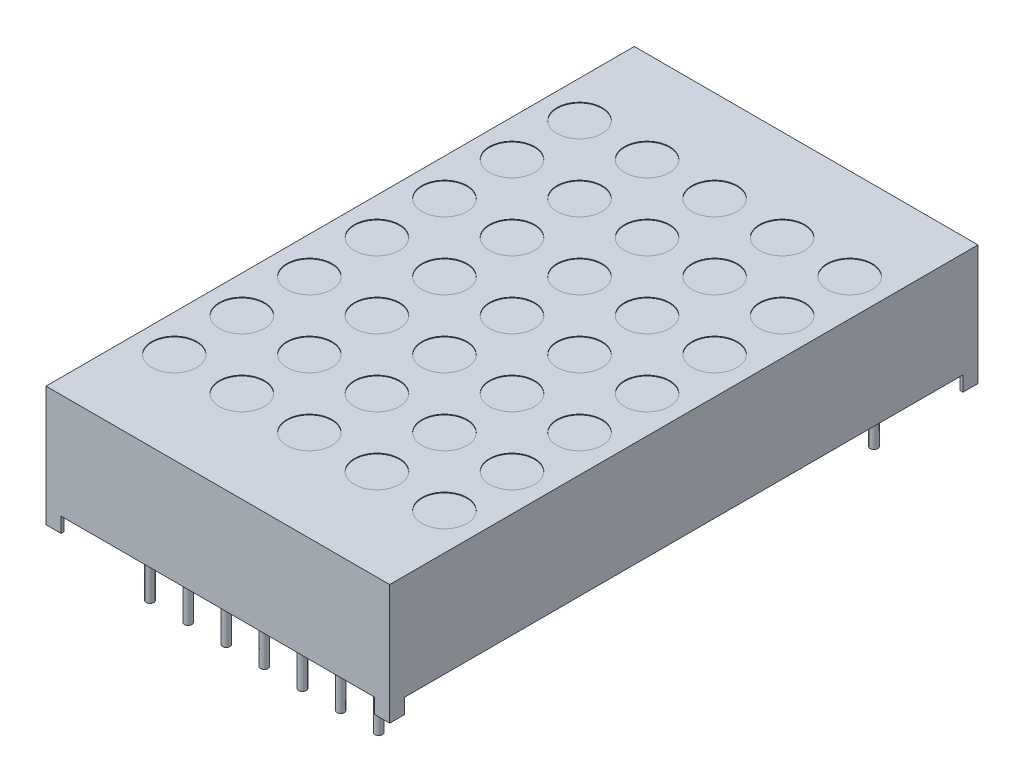
from build123d import *
from build123d.topology import SkipClean

# Parameters (mm, degrees)
EXTRUDE1_DEPTH     = 11.45
SKETCH3_W          = 20.9
SKETCH3_H          = 1
CUT_EXTRUDE1_DEPTH = 40.2
SKETCH2_R          = 1.5
CUT_EXTRUDE2_DEPTH = 0.05
SKETCH4_R          = 0.25
EXTRUDE2_DEPTH     = 1
SKETCH4_3_R        = 0.25
EXTRUDE3_DEPTH     = 4
SKETCH4_4_W        = 0.8
SKETCH4_4_H        = 0.8
CUT_EXTRUDE3_DEPTH = 1
SKETCH5_W          = 0.025316456
SKETCH5_H          = 0.026582279
CUT_EXTRUDE4_DEPTH = 0.01


with BuildPart() as part:
    # Sketch1 → Extrude1 (new body, symmetric)
    with BuildSketch(Plane(origin=(0, 0, 0), x_dir=(0, 0, -1), z_dir=(1, 0, 0))):
        Polygon((19.6, 4), (-19.6, 4), (14.7, -3), (18.6, -3), (18.6, -3.795918367), (19.6, -4), align=None)
        Polygon((14.7, -3), (-19.6, 4), (-19.6, -4), (-18.6, -4), (-18.6, -3), align=None)
        Polygon((19.6, -4), (18.6, -3.795918367), (18.6, -4), align=None)
    extrude(amount=EXTRUDE1_DEPTH, both=True)

    # Sketch3 → Cut-Extrude1 (cut, through all)
    with BuildSketch(Plane.XY.offset(19.6)):
        with Locations((0, -3.5)):
            Rectangle(SKETCH3_W, SKETCH3_H)
    extrude(amount=-CUT_EXTRUDE1_DEPTH, mode=Mode.SUBTRACT)

    # Sketch2 → Cut-Extrude2 (cut)
    with BuildSketch(Plane(origin=(0, 4, 0), x_dir=(-1, 0, 0), z_dir=(0, 1, 0))):
        with Locations(Location((9, -13.5, 0), (0, 0, 90))):  # turned: the seam where the file's is
            Circle(SKETCH2_R)
        with Locations(Location((4.5, -13.5, 0), (0, 0, 90))):  # turned: the seam where the file's is
            Circle(SKETCH2_R)
        with Locations(Location((0, -13.5, 0), (0, 0, 90))):  # turned: the seam where the file's is
            Circle(SKETCH2_R)
        with Locations(Location((-4.5, -13.5, 0), (0, 0, 90))):  # turned: the seam where the file's is
            Circle(SKETCH2_R)
        with Locations(Location((-9, -13.5, 0), (0, 0, 90))):  # turned: the seam where the file's is
            Circle(SKETCH2_R)
        with Locations(Location((-9, -9, 0), (0, 0, 90))):  # turned: the seam where the file's is
            Circle(SKETCH2_R)
        with Locations(Location((-4.5, -9, 0), (0, 0, 90))):  # turned: the seam where the file's is
            Circle(SKETCH2_R)
        with Locations(Location((0, -9, 0), (0, 0, 90))):  # turned: the seam where the file's is
            Circle(SKETCH2_R)
        with Locations(Location((4.5, -9, 0), (0, 0, 90))):  # turned: the seam where the file's is
            Circle(SKETCH2_R)
        with Locations(Location((9, -9, 0), (0, 0, 90))):  # turned: the seam where the file's is
            Circle(SKETCH2_R)
        with Locations(Location((9, -4.5, 0), (0, 0, 90))):  # turned: the seam where the file's is
            Circle(SKETCH2_R)
        with Locations(Location((4.5, -4.5, 0), (0, 0, 90))):  # turned: the seam where the file's is
            Circle(SKETCH2_R)
        with Locations(Location((0, -4.5, 0), (0, 0, 90))):  # turned: the seam where the file's is
            Circle(SKETCH2_R)
        with Locations(Location((-4.5, -4.5, 0), (0, 0, 90))):  # turned: the seam where the file's is
            Circle(SKETCH2_R)
        with Locations(Location((-9, -4.5, 0), (0, 0, 90))):  # turned: the seam where the file's is
            Circle(SKETCH2_R)
        with Locations(Location((-9, 0, 0), (0, 0, 90))):  # turned: the seam where the file's is
            Circle(SKETCH2_R)
        with Locations(Location((-4.5, 0, 0), (0, 0, 90))):  # turned: the seam where the file's is
            Circle(SKETCH2_R)
        with Locations(Location((0, 0, 0), (0, 0, 90))):  # turned: the seam where the file's is
            Circle(SKETCH2_R)
        with Locations(Location((4.5, 0, 0), (0, 0, 90))):  # turned: the seam where the file's is
            Circle(SKETCH2_R)
        with Locations(Location((9, 0, 0), (0, 0, 90))):  # turned: the seam where the file's is
            Circle(SKETCH2_R)
        with Locations(Location((9, 4.5, 0), (0, 0, 90))):  # turned: the seam where the file's is
            Circle(SKETCH2_R)
        with Locations(Location((4.5, 4.5, 0), (0, 0, 90))):  # turned: the seam where the file's is
            Circle(SKETCH2_R)
        with Locations(Location((0, 4.5, 0), (0, 0, 90))):  # turned: the seam where the file's is
            Circle(SKETCH2_R)
        with Locations(Location((-4.5, 4.5, 0), (0, 0, 90))):  # turned: the seam where the file's is
            Circle(SKETCH2_R)
        with Locations(Location((-9, 4.5, 0), (0, 0, 90))):  # turned: the seam where the file's is
            Circle(SKETCH2_R)
        with Locations(Location((-9, 9, 0), (0, 0, 90))):  # turned: the seam where the file's is
            Circle(SKETCH2_R)
        with Locations(Location((-4.5, 9, 0), (0, 0, 90))):  # turned: the seam where the file's is
            Circle(SKETCH2_R)
        with Locations(Location((0, 9, 0), (0, 0, 90))):  # turned: the seam where the file's is
            Circle(SKETCH2_R)
        with Locations(Location((4.5, 9, 0), (0, 0, 90))):  # turned: the seam where the file's is
            Circle(SKETCH2_R)
        with Locations(Location((9, 9, 0), (0, 0, 90))):  # turned: the seam where the file's is
            Circle(SKETCH2_R)
        with Locations(Location((9, 13.5, 0), (0, 0, 90))):  # turned: the seam where the file's is
            Circle(SKETCH2_R)
        with Locations(Location((4.5, 13.5, 0), (0, 0, 90))):  # turned: the seam where the file's is
            Circle(SKETCH2_R)
        with Locations(Location((0, 13.5, 0), (0, 0, 90))):  # turned: the seam where the file's is
            Circle(SKETCH2_R)
        with Locations(Location((-4.5, 13.5, 0), (0, 0, 90))):  # turned: the seam where the file's is
            Circle(SKETCH2_R)
        with Locations(Location((-9, 13.5, 0), (0, 0, 90))):  # turned: the seam where the file's is
            Circle(SKETCH2_R)
    extrude(amount=-CUT_EXTRUDE2_DEPTH, mode=Mode.SUBTRACT)

    # Sketch4 → Extrude2 (add)
    with BuildSketch(Plane.XZ.offset(4)):
        with Locations((-7.62, 16.5)):
            Circle(SKETCH4_R)
        with Locations(Location((-5.08, 16.5, 0), (0, 0, 90))):  # turned: the seam where the file's is
            Circle(SKETCH4_R)
        with Locations(Location((-2.54, 16.5, 0), (0, 0, 90))):  # turned: the seam where the file's is
            Circle(SKETCH4_R)
        with Locations(Location((7.62, 16.5, 0), (0, 0, 90))):  # turned: the seam where the file's is
            Circle(SKETCH4_R)
        with Locations(Location((0, 16.5, 0), (0, 0, 90))):  # turned: the seam where the file's is
            Circle(SKETCH4_R)
        with Locations(Location((2.54, 16.5, 0), (0, 0, 90))):  # turned: the seam where the file's is
            Circle(SKETCH4_R)
        with Locations(Location((5.08, 16.5, 0), (0, 0, 90))):  # turned: the seam where the file's is
            Circle(SKETCH4_R)
        with Locations(Location((5.08, -16.5, 0), (0, 0, 90))):  # turned: the seam where the file's is
            Circle(SKETCH4_R)
        with Locations(Location((2.54, -16.5, 0), (0, 0, 90))):  # turned: the seam where the file's is
            Circle(SKETCH4_R)
        with Locations(Location((0, -16.5, 0), (0, 0, 90))):  # turned: the seam where the file's is
            Circle(SKETCH4_R)
        with Locations(Location((7.62, -16.5, 0), (0, 0, 90))):  # turned: the seam where the file's is
            Circle(SKETCH4_R)
        with Locations(Location((-2.54, -16.5, 0), (0, 0, 90))):  # turned: the seam where the file's is
            Circle(SKETCH4_R)
        with Locations(Location((-5.08, -16.5, 0), (0, 0, 90))):  # turned: the seam where the file's is
            Circle(SKETCH4_R)
        with Locations(Location((-7.62, -16.5, 0), (0, 0, 90))):  # turned: the seam where the file's is
            Circle(SKETCH4_R)
    extrude(amount=-EXTRUDE2_DEPTH)

    # Sketch4_3 → Extrude3 (add)
    with SkipClean():  # keep this step's faces unmerged: merging them makes the solid invalid here
        with BuildSketch(Plane.XZ.offset(4)):
            with Locations((-7.62, 16.5)):
                Circle(SKETCH4_3_R)
            with Locations((-5.08, 16.5)):
                Circle(SKETCH4_3_R)
            with Locations((-2.54, 16.5)):
                Circle(SKETCH4_3_R)
            with Locations((7.62, 16.5)):
                Circle(SKETCH4_3_R)
            with Locations((0, 16.5)):
                Circle(SKETCH4_3_R)
            with Locations((2.54, 16.5)):
                Circle(SKETCH4_3_R)
            with Locations(Location((5.08, 16.5, 0), (0, 0, 90))):  # turned: the seam where the file's is
                Circle(SKETCH4_3_R)
            with Locations(Location((5.08, -16.5, 0), (0, 0, 180))):  # turned: the seam where the file's is
                Circle(SKETCH4_3_R)
            with Locations(Location((2.54, -16.5, 0), (0, 0, 180))):  # turned: the seam where the file's is
                Circle(SKETCH4_3_R)
            with Locations(Location((0, -16.5, 0), (0, 0, 180))):  # turned: the seam where the file's is
                Circle(SKETCH4_3_R)
            with Locations(Location((7.62, -16.5, 0), (0, 0, 180))):  # turned: the seam where the file's is
                Circle(SKETCH4_3_R)
            with Locations(Location((-2.54, -16.5, 0), (0, 0, 90))):  # turned: the seam where the file's is
                Circle(SKETCH4_3_R)
            with Locations(Location((-5.08, -16.5, 0), (0, 0, 90))):  # turned: the seam where the file's is
                Circle(SKETCH4_3_R)
            with Locations(Location((-7.62, -16.5, 0), (0, 0, 90))):  # turned: the seam where the file's is
                Circle(SKETCH4_3_R)
        extrude(amount=EXTRUDE3_DEPTH)

    # Sketch4_4 → Cut-Extrude3 (cut)
    with SkipClean():  # keep this step's faces unmerged: merging them makes the solid invalid here
        with BuildSketch(Plane.XZ.offset(4)):
            with Locations((-10.85, 19)):
                Rectangle(SKETCH4_4_W, SKETCH4_4_H)
            with Locations((10.85, 19)):
                Rectangle(SKETCH4_4_W, SKETCH4_4_H)
            with Locations((10.85, -19)):
                Rectangle(SKETCH4_4_W, SKETCH4_4_H)
            with Locations((-10.85, -19)):
                Rectangle(SKETCH4_4_W, SKETCH4_4_H)
        extrude(amount=-CUT_EXTRUDE3_DEPTH, mode=Mode.SUBTRACT)

    # Sketch5 → Cut-Extrude4 (cut)
    with SkipClean():  # keep this step's faces unmerged: merging them makes the solid invalid here
        with BuildSketch(Plane.XZ.offset(3)):
            Polygon((0.572151899, 16.06631939), (0.595609177, 16.141002935), (0.620352057, 16.141002935), (0.636768196, 16.0906667), (0.652294304, 16.141002935), (0.678026108, 16.141002935), (0.701265823, 16.06631939), (0.676087816, 16.06631939), (0.663093354, 16.117802776), (0.646677215, 16.06631939), (0.625178006, 16.06631939), (0.608860759, 16.117802776), (0.596044304, 16.06631939), align=None)
            Polygon((0.437974684, 16.06631939), (0.461431962, 16.141002935), (0.486174842, 16.141002935), (0.502590981, 16.0906667), (0.518117089, 16.141002935), (0.543848892, 16.141002935), (0.567088608, 16.06631939), (0.541910601, 16.06631939), (0.528916139, 16.117802776), (0.5125, 16.06631939), (0.491000791, 16.06631939), (0.474683544, 16.117802776), (0.461867089, 16.06631939), align=None)
            Polygon((0.303797468, 16.06631939), (0.327254747, 16.141002935), (0.351997627, 16.141002935), (0.368413766, 16.0906667), (0.383939873, 16.141002935), (0.409671677, 16.141002935), (0.432911392, 16.06631939), (0.407733386, 16.06631939), (0.394738924, 16.117802776), (0.378322785, 16.06631939), (0.356823576, 16.06631939), (0.340506329, 16.117802776), (0.327689873, 16.06631939), align=None)
            with Locations((0.275949367, 16.127711795)):
                Rectangle(SKETCH5_W, SKETCH5_H)
            with BuildLine():
                add(Edge.make_bspline(
                    [(0.159493671, 16.109832048), (0.159530199, 16.111054163), (0.159601928, 16.113453987), (0.16021109, 16.116961953), (0.161206614, 16.120285236), (0.162570953, 16.123447952), (0.164384941, 16.126403318), (0.166539954, 16.129221885), (0.169151869, 16.131805846), (0.172088905, 16.134244608), (0.175386832, 16.136427002), (0.178989454, 16.138327141), (0.182859774, 16.139951859), (0.187013794, 16.141283549), (0.191459372, 16.142274316), (0.196177149, 16.142997634), (0.201170497, 16.143471141), (0.204594085, 16.143513083), (0.206348892, 16.14353458)],
                    knots=[0, 0, 0, 0, 0.907421153, 1.781872267, 2.635683434, 3.480115191, 4.332689235, 5.205575272, 6.109500117, 7.055808355, 8.037942167, 9.041423561, 10.07750834, 11.152467461, 12.277657752, 13.45734338, 14.696726425, 16, 16, 16, 16], degree=3))
                add(Edge.make_bspline(
                    [(0.206348892, 16.14353458), (0.208366877, 16.143507315), (0.212275063, 16.143454512), (0.217942631, 16.143069139), (0.223206098, 16.142381189), (0.228103845, 16.141424609), (0.232708145, 16.140221323), (0.23714149, 16.13893068), (0.241422782, 16.137466099), (0.244195874, 16.136365963), (0.24556962, 16.135820973)],
                    knots=[0, 0, 0, 0, 1.203182053, 2.33017619, 3.384818652, 4.366208123, 5.30340534, 6.221361684, 7.118890722, 8, 8, 8, 8], degree=3))
                Line((0.24556962, 16.135820973), (0.24556962, 16.11188901))
                Line((0.24556962, 16.11188901), (0.242721519, 16.11188901))
                add(Edge.make_bspline(
                    [(0.242721519, 16.11188901), (0.241355956, 16.112969973), (0.238632846, 16.115125552), (0.234205888, 16.117893907), (0.229546876, 16.120266917), (0.224708482, 16.12224954), (0.219807114, 16.123825154), (0.214938046, 16.124952059), (0.210169064, 16.125691424), (0.207010742, 16.125772985), (0.205458861, 16.125813061)],
                    knots=[0, 0, 0, 0, 1.030738938, 2.055426519, 3.085610749, 4.123842265, 5.148648843, 6.130724483, 7.081507926, 8, 8, 8, 8], degree=3))
                add(Edge.make_bspline(
                    [(0.205458861, 16.125813061), (0.205030115, 16.12581176), (0.204112202, 16.125808976), (0.202643054, 16.125687661), (0.200986711, 16.125559817), (0.199205972, 16.125363702), (0.197418768, 16.125132558), (0.19575852, 16.12478609), (0.194257758, 16.124416939), (0.193351089, 16.124049674), (0.192919304, 16.12387477)],
                    knots=[0, 0, 0, 0, 0.806537132, 1.726733348, 2.77251655, 3.932999672, 5.098049949, 6.161349231, 7.124375527, 8, 8, 8, 8], degree=3))
                add(Edge.make_bspline(
                    [(0.192919304, 16.12387477), (0.192439817, 16.123646534), (0.191497525, 16.123198003), (0.190194994, 16.122384093), (0.189024509, 16.121489348), (0.187963807, 16.120527615), (0.187101412, 16.119364627), (0.186480251, 16.117965356), (0.18613568, 16.116316063), (0.186096608, 16.115140901), (0.186075949, 16.114519548)],
                    knots=[0, 0, 0, 0, 1.02474257, 2.013837243, 2.958431669, 3.867978675, 4.769292696, 5.732237074, 6.800947934, 8, 8, 8, 8], degree=3))
                add(Edge.make_bspline(
                    [(0.186075949, 16.114519548), (0.186107411, 16.113973682), (0.186169273, 16.112900348), (0.186750779, 16.111371919), (0.187634826, 16.109951783), (0.188914241, 16.108686446), (0.190527919, 16.107560335), (0.192458907, 16.106549571), (0.194732757, 16.105713814), (0.19636997, 16.105275942), (0.197231013, 16.105045656)],
                    knots=[0, 0, 0, 0, 0.825427492, 1.623033598, 2.45033906, 3.348940377, 4.33183287, 5.428402891, 6.647546779, 8, 8, 8, 8], degree=3))
                add(Edge.make_bspline(
                    [(0.197231013, 16.105045656), (0.199200253, 16.104600451), (0.203235465, 16.103688173), (0.209375278, 16.102500719), (0.215513981, 16.101274849), (0.219470238, 16.100060534), (0.221400316, 16.099468124)],
                    knots=[0, 0, 0, 0, 0.976118991, 2.000185432, 3.024380873, 4, 4, 4, 4], degree=3))
                add(Edge.make_bspline(
                    [(0.221400316, 16.099468124), (0.222438469, 16.099114402), (0.224459331, 16.098425847), (0.227358523, 16.097273199), (0.230001771, 16.095968065), (0.23245931, 16.094646026), (0.234651974, 16.093165969), (0.236646608, 16.09163321), (0.238399268, 16.089980405), (0.239925706, 16.088230913), (0.241268572, 16.086394551), (0.242421982, 16.084447409), (0.243383004, 16.08238096), (0.244206396, 16.080225563), (0.244817623, 16.077951027), (0.245240059, 16.07557461), (0.245538122, 16.073091124), (0.245558978, 16.071396788), (0.24556962, 16.070532207)],
                    knots=[0, 0, 0, 0, 1.287376879, 2.505999703, 3.65855109, 4.746193839, 5.778582289, 6.760029101, 7.696159662, 8.601061861, 9.48181646, 10.363080883, 11.252765705, 12.153987336, 13.068239035, 14.012364187, 14.985753787, 16, 16, 16, 16], degree=3))
                add(Edge.make_bspline(
                    [(0.24556962, 16.070532207), (0.24553232, 16.06937606), (0.245458913, 16.067100785), (0.244857463, 16.063771763), (0.243830953, 16.060622944), (0.242444593, 16.057619788), (0.2406171, 16.054805525), (0.238424977, 16.052128039), (0.235814667, 16.049635543), (0.23282934, 16.047336906), (0.229542493, 16.0452581), (0.226008488, 16.043421393), (0.222229636, 16.041914945), (0.218249751, 16.040633714), (0.214030359, 16.039681319), (0.209593388, 16.038961741), (0.204919526, 16.038548741), (0.201728115, 16.038497465), (0.200098892, 16.038471289)],
                    knots=[0, 0, 0, 0, 0.894901293, 1.761149761, 2.608783409, 3.453876344, 4.314933854, 5.200038827, 6.12799933, 7.103249695, 8.113098521, 9.136064399, 10.182719798, 11.259667356, 12.370545059, 13.528828137, 14.738461593, 16, 16, 16, 16], degree=3))
                add(Edge.make_bspline(
                    [(0.200098892, 16.038471289), (0.198430241, 16.038493682), (0.195095767, 16.038538429), (0.190113794, 16.038913399), (0.185156379, 16.0394799), (0.180284815, 16.040279355), (0.175602308, 16.04129701), (0.171185694, 16.042382968), (0.167106724, 16.043623358), (0.164532999, 16.044577404), (0.163291139, 16.045037745)],
                    knots=[0, 0, 0, 0, 1.065379838, 2.128953261, 3.188461447, 4.250817766, 5.279613205, 6.247547721, 7.154416075, 8, 8, 8, 8], degree=3))
                Line((0.163291139, 16.045037745), (0.163291139, 16.067585213))
                Line((0.163291139, 16.067585213), (0.166119462, 16.067585213))
                add(Edge.make_bspline(
                    [(0.166119462, 16.067585213), (0.167192422, 16.066785009), (0.169386652, 16.065148571), (0.173045405, 16.063062595), (0.177009465, 16.061113081), (0.181274367, 16.059391287), (0.185746907, 16.057970687), (0.190324453, 16.056941642), (0.194951518, 16.056302519), (0.198053109, 16.056229387), (0.19960443, 16.056192808)],
                    knots=[0, 0, 0, 0, 0.89224925, 1.824673196, 2.804309561, 3.838364047, 4.890042674, 5.931526337, 6.965412421, 8, 8, 8, 8], degree=3))
                add(Edge.make_bspline(
                    [(0.19960443, 16.056192808), (0.20069973, 16.056217018), (0.202889476, 16.056265418), (0.206163883, 16.056614672), (0.209398675, 16.057286414), (0.211441573, 16.05810075), (0.212460443, 16.05850689)],
                    knots=[0, 0, 0, 0, 0.998993879, 1.997209027, 3.00113285, 4, 4, 4, 4], degree=3))
                add(Edge.make_bspline(
                    [(0.212460443, 16.05850689), (0.212893922, 16.058708373), (0.213760592, 16.059111204), (0.214967595, 16.05988353), (0.216070899, 16.060813248), (0.217071904, 16.061865642), (0.21791996, 16.063034977), (0.21855762, 16.064304736), (0.218918439, 16.065666714), (0.218964276, 16.066600883), (0.218987342, 16.067070973)],
                    knots=[0, 0, 0, 0, 1.005454979, 2.010239304, 3.005296729, 4.036100111, 5.060531193, 6.034954812, 7.011155677, 8, 8, 8, 8], degree=3))
                add(Edge.make_bspline(
                    [(0.218987342, 16.067070973), (0.218952547, 16.067708903), (0.218886059, 16.068927931), (0.218286061, 16.070641628), (0.217288392, 16.072104739), (0.216135293, 16.073097733), (0.215018314, 16.073796493), (0.213977797, 16.074301732), (0.212778346, 16.074815155), (0.211400897, 16.075304352), (0.209865762, 16.075798399), (0.20815684, 16.076273069), (0.206274232, 16.076722628), (0.204958342, 16.07700878), (0.204272152, 16.077157998)],
                    knots=[0, 0, 0, 0, 1.174343879, 2.244064321, 3.303704314, 4.407076671, 5.02483983, 5.732197225, 6.53898402, 7.431906431, 8.428480183, 9.514816237, 10.704066255, 12, 12, 12, 12], degree=3))
                add(Edge.make_bspline(
                    [(0.204272152, 16.077157998), (0.202439527, 16.077534718), (0.198838824, 16.07827489), (0.193433749, 16.079369187), (0.187940695, 16.080681704), (0.184270145, 16.081810916), (0.182357595, 16.082399295)],
                    knots=[0, 0, 0, 0, 0.995788186, 1.956503735, 2.935230479, 4, 4, 4, 4], degree=3))
                add(Edge.make_bspline(
                    [(0.182357595, 16.082399295), (0.181411038, 16.082718537), (0.179559421, 16.083343024), (0.176918823, 16.084429343), (0.17447165, 16.0856032), (0.172205016, 16.086845169), (0.17012965, 16.088187603), (0.16824336, 16.089612936), (0.166545403, 16.091117718), (0.165056655, 16.092733438), (0.163727897, 16.094443787), (0.162615553, 16.0962944), (0.161619968, 16.098237929), (0.160866813, 16.100331372), (0.160242304, 16.102529899), (0.159820561, 16.104861834), (0.159526198, 16.107306052), (0.159504634, 16.108980651), (0.159493671, 16.109832048)],
                    knots=[0, 0, 0, 0, 1.237326419, 2.420410185, 3.534642089, 4.598489486, 5.620241961, 6.59385002, 7.525152549, 8.426792174, 9.312230456, 10.203151844, 11.098070343, 12.012931196, 12.954244379, 13.926618287, 14.945853925, 16, 16, 16, 16], degree=3))
            make_face()
            with BuildLine():
                Line((0.067088608, 16.141002935), (0.091139241, 16.141002935))
                Line((0.091139241, 16.141002935), (0.091139241, 16.133170656))
                add(Edge.make_bspline(
                    [(0.091139241, 16.133170656), (0.092232434, 16.133979451), (0.094340096, 16.135538796), (0.097514655, 16.137615857), (0.100532955, 16.13940028), (0.103463307, 16.140923397), (0.106469584, 16.142135568), (0.109707718, 16.142953948), (0.113209314, 16.143456672), (0.115636384, 16.143508034), (0.116890823, 16.14353458)],
                    knots=[0, 0, 0, 0, 1.150945962, 2.219006967, 3.209666795, 4.118194914, 5.012574058, 5.946577101, 6.93868214, 8, 8, 8, 8], degree=3))
                add(Edge.make_bspline(
                    [(0.116890823, 16.14353458), (0.117907098, 16.143511632), (0.119886079, 16.143466946), (0.122764378, 16.143125225), (0.125466344, 16.142576816), (0.127995181, 16.14180841), (0.130344881, 16.140805379), (0.132488561, 16.139533744), (0.134491138, 16.138101031), (0.136273085, 16.136394665), (0.137888631, 16.134496746), (0.139271202, 16.132364337), (0.140448907, 16.130031398), (0.141390007, 16.127479548), (0.142145096, 16.124721243), (0.142669028, 16.121741996), (0.142989621, 16.118554868), (0.14302156, 16.116359738), (0.143037975, 16.115231574)],
                    knots=[0, 0, 0, 0, 1.108959949, 2.159465255, 3.158589008, 4.114545495, 5.039534357, 5.93921201, 6.830099133, 7.720870013, 8.624681761, 9.544731627, 10.487599671, 11.471264588, 12.508152322, 13.604835107, 14.769030043, 16, 16, 16, 16], degree=3))
                Line((0.143037975, 16.115231574), (0.143037975, 16.06631939))
                Line((0.143037975, 16.06631939), (0.118987342, 16.06631939))
                Line((0.118987342, 16.06631939), (0.118987342, 16.103898504))
                add(Edge.make_bspline(
                    [(0.118987342, 16.103898504), (0.118985706, 16.104814975), (0.118982576, 16.106569191), (0.118900237, 16.109074997), (0.118779336, 16.11134317), (0.118640631, 16.113385198), (0.118387615, 16.115231949), (0.118009906, 16.11689811), (0.11753908, 16.118417712), (0.117074761, 16.119324414), (0.116851266, 16.119760846)],
                    knots=[0, 0, 0, 0, 1.361401701, 2.605856924, 3.723918663, 4.735739235, 5.645738665, 6.489217889, 7.27279937, 8, 8, 8, 8], degree=3))
                add(Edge.make_bspline(
                    [(0.116851266, 16.119760846), (0.116621257, 16.120159552), (0.11616908, 16.120943373), (0.115248816, 16.121949684), (0.114169974, 16.122793434), (0.11289277, 16.123451535), (0.111403203, 16.123942038), (0.109682344, 16.12432261), (0.107690603, 16.124494487), (0.106283135, 16.124528978), (0.105537975, 16.124547238)],
                    knots=[0, 0, 0, 0, 0.849004071, 1.669068917, 2.503060811, 3.370079215, 4.310762265, 5.396376419, 6.621555549, 8, 8, 8, 8], degree=3))
                add(Edge.make_bspline(
                    [(0.105537975, 16.124547238), (0.104997032, 16.124527399), (0.103885616, 16.124486638), (0.102168163, 16.124295097), (0.100378903, 16.123895938), (0.097860234, 16.123250994), (0.094695025, 16.122057139), (0.09233549, 16.120703992), (0.091139241, 16.120017966)],
                    knots=[0, 0, 0, 0, 0.638062719, 1.310959128, 2.033463623, 2.796942592, 4.376095945, 6, 6, 6, 6], degree=3))
                Line((0.091139241, 16.120017966), (0.091139241, 16.06631939))
                Line((0.091139241, 16.06631939), (0.067088608, 16.06631939))
                Line((0.067088608, 16.06631939), (0.067088608, 16.141002935))
            make_face()
            with BuildLine():
                Line((-0.030379747, 16.141002935), (-0.006329114, 16.141002935))
                Line((-0.006329114, 16.141002935), (-0.006329114, 16.103423821))
                add(Edge.make_bspline(
                    [(-0.006329114, 16.103423821), (-0.006304108, 16.101893831), (-0.006254136, 16.09883634), (-0.005977585, 16.095073246), (-0.005593098, 16.092231706), (-0.005225559, 16.090400117), (-0.004793687, 16.088852001), (-0.004381426, 16.087966239), (-0.004193038, 16.087561479)],
                    knots=[0, 0, 0, 0, 1.709111167, 3.415443484, 4.21113913, 4.910175115, 5.501990373, 6, 6, 6, 6], degree=3))
                add(Edge.make_bspline(
                    [(-0.004193038, 16.087561479), (-0.003948577, 16.087163416), (-0.003469277, 16.086382958), (-0.002531926, 16.085370081), (-0.001438143, 16.084540713), (-0.000166967, 16.083861246), (0.001321142, 16.083382058), (0.003045059, 16.083029304), (0.005025244, 16.08281875), (0.006434073, 16.082790196), (0.007179589, 16.082775086)],
                    knots=[0, 0, 0, 0, 0.860202684, 1.686548532, 2.528236983, 3.382486038, 4.33249885, 5.401154041, 6.624757403, 8, 8, 8, 8], degree=3))
                add(Edge.make_bspline(
                    [(0.007179589, 16.082775086), (0.008310478, 16.082835187), (0.010618173, 16.082957828), (0.013493483, 16.083624495), (0.015810821, 16.084484459), (0.017668538, 16.085234894), (0.01957626, 16.086208995), (0.020855802, 16.086930436), (0.021518987, 16.087304359)],
                    knots=[0, 0, 0, 0, 1.33818541, 2.730705359, 3.468371228, 4.262126284, 5.099261778, 6, 6, 6, 6], degree=3))
                Line((0.021518987, 16.087304359), (0.021518987, 16.141002935))
                Line((0.021518987, 16.141002935), (0.04556962, 16.141002935))
                Line((0.04556962, 16.141002935), (0.04556962, 16.06631939))
                Line((0.04556962, 16.06631939), (0.021518987, 16.06631939))
                Line((0.021518987, 16.06631939), (0.021518987, 16.074151669))
                add(Edge.make_bspline(
                    [(0.021518987, 16.074151669), (0.020461581, 16.073345517), (0.018403276, 16.071776295), (0.015224038, 16.069735875), (0.01214014, 16.067937105), (0.009087131, 16.066424289), (0.005972176, 16.065217514), (0.002709417, 16.064406525), (-0.000706989, 16.063862722), (-0.003043704, 16.063813028), (-0.004232595, 16.063787745)],
                    knots=[0, 0, 0, 0, 1.126119141, 2.192057864, 3.198061997, 4.149848529, 5.076251285, 6.021887753, 6.99356175, 8, 8, 8, 8], degree=3))
                add(Edge.make_bspline(
                    [(-0.004232595, 16.063787745), (-0.00522886, 16.063813145), (-0.007173746, 16.063862731), (-0.010008596, 16.064172283), (-0.012679702, 16.064723506), (-0.015173087, 16.065519363), (-0.017508773, 16.066510722), (-0.019682445, 16.067714701), (-0.021668294, 16.069177982), (-0.023496446, 16.070837921), (-0.025135546, 16.072729218), (-0.026532456, 16.074858596), (-0.027736818, 16.077195517), (-0.028686083, 16.079758154), (-0.029477407, 16.082524426), (-0.02998217, 16.085523056), (-0.030339823, 16.088732941), (-0.030366173, 16.090949091), (-0.030379747, 16.092090751)],
                    knots=[0, 0, 0, 0, 1.08828964, 2.12453497, 3.110382522, 4.062402335, 4.978696626, 5.878225494, 6.769849763, 7.667011675, 8.57076823, 9.495541561, 10.442454184, 11.436213583, 12.475881554, 13.580560132, 14.753614518, 16, 16, 16, 16], degree=3))
                Line((-0.030379747, 16.092090751), (-0.030379747, 16.141002935))
            make_face()
            Polygon((-0.125316456, 16.141002935), (-0.053164557, 16.141002935), (-0.053164557, 16.041002935), (-0.078481013, 16.041002935), (-0.078481013, 16.122015593), (-0.125316456, 16.122015593), align=None)
            Polygon((-0.212658228, 16.141002935), (-0.140506329, 16.141002935), (-0.140506329, 16.041002935), (-0.212658228, 16.041002935), (-0.212658228, 16.059990276), (-0.165822785, 16.059990276), (-0.165822785, 16.077711795), (-0.208860759, 16.077711795), (-0.208860759, 16.096699137), (-0.165822785, 16.096699137), (-0.165822785, 16.122015593), (-0.212658228, 16.122015593), align=None)
            with BuildLine():
                add(Edge.make_bspline(
                    [(-0.329113924, 16.091101827), (-0.329094609, 16.092249516), (-0.329056357, 16.094522402), (-0.328761165, 16.097887209), (-0.32823514, 16.101152884), (-0.327555959, 16.104337132), (-0.326633453, 16.10741606), (-0.325551739, 16.110423637), (-0.324242093, 16.113329131), (-0.322737241, 16.116130565), (-0.321087768, 16.118802668), (-0.319313019, 16.121322877), (-0.31746724, 16.123706095), (-0.315477927, 16.125900989), (-0.313398746, 16.127943008), (-0.311223217, 16.129833822), (-0.308918153, 16.131537253), (-0.30731099, 16.132560138), (-0.30650712, 16.133071764)],
                    knots=[0, 0, 0, 0, 1.105570398, 2.18947457, 3.250358341, 4.290584537, 5.323553275, 6.344225964, 7.367641686, 8.3905646, 9.405808457, 10.390761353, 11.358902336, 12.307789878, 13.241960776, 14.165076779, 15.082208636, 16, 16, 16, 16], degree=3))
                add(Edge.make_bspline(
                    [(-0.30650712, 16.133071764), (-0.305267933, 16.133784085), (-0.302783236, 16.135212362), (-0.298798778, 16.136878201), (-0.294677169, 16.138292424), (-0.290317988, 16.139305864), (-0.285679267, 16.140075699), (-0.280674456, 16.140623871), (-0.27526755, 16.140929373), (-0.271532557, 16.140977855), (-0.269600475, 16.141002935)],
                    knots=[0, 0, 0, 0, 0.896321744, 1.797216976, 2.705381885, 3.628777036, 4.602292017, 5.655629376, 6.787275635, 8, 8, 8, 8], degree=3))
                Line((-0.269600475, 16.141002935), (-0.234177215, 16.141002935))
                Line((-0.234177215, 16.141002935), (-0.234177215, 16.041002935))
                Line((-0.234177215, 16.041002935), (-0.270609177, 16.041002935))
                add(Edge.make_bspline(
                    [(-0.270609177, 16.041002935), (-0.272587873, 16.041019745), (-0.276404533, 16.041052169), (-0.281921849, 16.041467097), (-0.287024188, 16.04207286), (-0.291713768, 16.042967045), (-0.296016217, 16.044081626), (-0.299933509, 16.045470158), (-0.303549742, 16.046962775), (-0.305728277, 16.048237329), (-0.306784019, 16.048854992)],
                    knots=[0, 0, 0, 0, 1.267083275, 2.444046388, 3.541868212, 4.55639609, 5.499737919, 6.385160515, 7.217431253, 8, 8, 8, 8], degree=3))
                add(Edge.make_bspline(
                    [(-0.306784019, 16.048854992), (-0.307634972, 16.049391532), (-0.309327097, 16.050458446), (-0.311728312, 16.052240298), (-0.313957739, 16.054196375), (-0.316086242, 16.056248194), (-0.318066059, 16.05845108), (-0.319909259, 16.060789788), (-0.321613076, 16.063267882), (-0.323171039, 16.065877351), (-0.324591854, 16.068607403), (-0.32578116, 16.071480462), (-0.326830509, 16.074458992), (-0.327636046, 16.077567954), (-0.32833396, 16.08077579), (-0.328768694, 16.084117134), (-0.329055305, 16.087569623), (-0.32909422, 16.089914512), (-0.329113924, 16.091101827)],
                    knots=[0, 0, 0, 0, 0.964065863, 1.917049184, 2.86229036, 3.805247319, 4.749389377, 5.698846072, 6.657678277, 7.629829384, 8.610569287, 9.604676042, 10.607940105, 11.6349849, 12.681042988, 13.752616828, 14.862056989, 16, 16, 16, 16], degree=3))
            make_face()
            with BuildLine():
                add(Edge.make_bspline(
                    [(-0.302531646, 16.090943599), (-0.302488343, 16.089365169), (-0.30240473, 16.086317369), (-0.301699336, 16.081921725), (-0.300560086, 16.077878775), (-0.299222393, 16.074766359), (-0.297885002, 16.072493042), (-0.296757478, 16.070894771), (-0.295507812, 16.069380572), (-0.294117203, 16.067971732), (-0.292582019, 16.066664696), (-0.29092076, 16.065435785), (-0.289120719, 16.064307139), (-0.287847688, 16.063647133), (-0.287203323, 16.063313061)],
                    knots=[0, 0, 0, 0, 1.694683197, 3.272273219, 4.767406206, 6.197615014, 6.895990032, 7.597410435, 8.296503208, 9.002591366, 9.720792421, 10.460154445, 11.220583224, 12, 12, 12, 12], degree=3))
                add(Edge.make_bspline(
                    [(-0.287203323, 16.063313061), (-0.286528388, 16.063006547), (-0.285190619, 16.062399014), (-0.283120344, 16.061664928), (-0.281027643, 16.0611026), (-0.278833415, 16.060630177), (-0.276356655, 16.060353041), (-0.273434164, 16.060140365), (-0.269977491, 16.060003437), (-0.267490895, 16.059994867), (-0.266159019, 16.059990276)],
                    knots=[0, 0, 0, 0, 0.826913061, 1.638999358, 2.447478739, 3.243919028, 4.140906711, 5.225381046, 6.513851968, 8, 8, 8, 8], degree=3))
                Line((-0.266159019, 16.059990276), (-0.259493671, 16.059990276))
                Line((-0.259493671, 16.059990276), (-0.259493671, 16.122015593))
                Line((-0.259493671, 16.122015593), (-0.266159019, 16.122015593))
                add(Edge.make_bspline(
                    [(-0.266159019, 16.122015593), (-0.26691721, 16.122010547), (-0.268380945, 16.122000806), (-0.270497399, 16.121961703), (-0.272462161, 16.121901387), (-0.274269511, 16.121829544), (-0.275925648, 16.121714641), (-0.277413482, 16.121546044), (-0.278755832, 16.121401657), (-0.280323467, 16.121134537), (-0.282176615, 16.120718082), (-0.284337881, 16.120039991), (-0.286478414, 16.119189571), (-0.287866987, 16.118504608), (-0.288568038, 16.118158789)],
                    knots=[0, 0, 0, 0, 1.186775798, 2.291144404, 3.313233901, 4.263515562, 5.122260739, 5.910868134, 6.60717912, 7.234883681, 8.398964994, 9.577230746, 10.776813768, 12, 12, 12, 12], degree=3))
                add(Edge.make_bspline(
                    [(-0.288568038, 16.118158789), (-0.289151752, 16.117815313), (-0.290299689, 16.117139829), (-0.291943833, 16.116033966), (-0.293430573, 16.114798967), (-0.294836635, 16.113515868), (-0.296089501, 16.112125415), (-0.297262794, 16.110674935), (-0.29827305, 16.109112542), (-0.299518045, 16.106919012), (-0.300737777, 16.103885642), (-0.301778537, 16.099919099), (-0.302415052, 16.095559089), (-0.302491785, 16.092521507), (-0.302531646, 16.090943599)],
                    knots=[0, 0, 0, 0, 0.755109416, 1.485004392, 2.205961541, 2.908125208, 3.605307969, 4.290649036, 4.985852759, 5.676964147, 7.100721462, 8.614478074, 10.241350405, 12, 12, 12, 12], degree=3))
            make_face(mode=Mode.SUBTRACT)
            with Locations((-0.360759494, 16.127711795)):
                Rectangle(SKETCH5_W, SKETCH5_H)
            with BuildLine():
                add(Edge.make_bspline(
                    [(-0.435403481, 16.14353458), (-0.433813375, 16.143512754), (-0.430692253, 16.143469912), (-0.426120809, 16.14299321), (-0.421756006, 16.142274743), (-0.417608387, 16.141256572), (-0.413701826, 16.139900229), (-0.410020773, 16.138282215), (-0.406631411, 16.136264409), (-0.404567681, 16.134687467), (-0.403540348, 16.13390246)],
                    knots=[0, 0, 0, 0, 1.123606455, 2.205459211, 3.245124445, 4.248821949, 5.220056174, 6.165006393, 7.086533249, 8, 8, 8, 8], degree=3))
                add(Edge.make_bspline(
                    [(-0.403540348, 16.13390246), (-0.402588601, 16.133047686), (-0.400688786, 16.131341443), (-0.398222853, 16.128370016), (-0.396099767, 16.125086972), (-0.394314215, 16.121484749), (-0.392883291, 16.117568021), (-0.391860157, 16.113323358), (-0.391240912, 16.108762578), (-0.391173746, 16.105614644), (-0.391139241, 16.103997397)],
                    knots=[0, 0, 0, 0, 0.916457077, 1.82937027, 2.759194969, 3.714948755, 4.706655623, 5.743329475, 6.840637961, 8, 8, 8, 8], degree=3))
                add(Edge.make_bspline(
                    [(-0.391139241, 16.103997397), (-0.391178001, 16.102294169), (-0.391253124, 16.098993089), (-0.391916883, 16.094220902), (-0.392986496, 16.089803221), (-0.394524054, 16.085751313), (-0.396454496, 16.082058121), (-0.398718989, 16.078686287), (-0.401339514, 16.075643362), (-0.403346653, 16.073897923), (-0.404351266, 16.073024295)],
                    knots=[0, 0, 0, 0, 1.171797512, 2.271099083, 3.308930235, 4.294129479, 5.24602549, 6.17106565, 7.084581485, 8, 8, 8, 8], degree=3))
                add(Edge.make_bspline(
                    [(-0.404351266, 16.073024295), (-0.405377179, 16.072255834), (-0.407441398, 16.070709629), (-0.410844242, 16.068807019), (-0.414471932, 16.067218825), (-0.418293668, 16.065942105), (-0.422268653, 16.064987488), (-0.426332207, 16.064294822), (-0.430476009, 16.06386614), (-0.433266389, 16.063814002), (-0.434671677, 16.063787745)],
                    knots=[0, 0, 0, 0, 0.952046378, 1.915591786, 2.889970712, 3.892742799, 4.906722985, 5.925995921, 6.955492795, 8, 8, 8, 8], degree=3))
                add(Edge.make_bspline(
                    [(-0.434671677, 16.063787745), (-0.435918482, 16.063804142), (-0.438370122, 16.063836385), (-0.441968962, 16.064166989), (-0.44542692, 16.064668926), (-0.448733839, 16.065407498), (-0.451900836, 16.066329115), (-0.454954975, 16.067361177), (-0.457914207, 16.068496409), (-0.459814852, 16.069380686), (-0.460759494, 16.069820181)],
                    knots=[0, 0, 0, 0, 1.107549047, 2.177816721, 3.208424937, 4.210433793, 5.185680559, 6.13785309, 7.074491882, 8, 8, 8, 8], degree=3))
                Line((-0.460759494, 16.069820181), (-0.460759494, 16.090370023))
                Line((-0.460759494, 16.090370023), (-0.45741693, 16.090370023))
                add(Edge.make_bspline(
                    [(-0.45741693, 16.090370023), (-0.456916353, 16.089954137), (-0.455831328, 16.089052685), (-0.454064496, 16.087606097), (-0.451894176, 16.086105807), (-0.450247147, 16.085211182), (-0.449367089, 16.084733156)],
                    knots=[0, 0, 0, 0, 0.792743043, 1.718305972, 2.780820752, 4, 4, 4, 4], degree=3))
                add(Edge.make_bspline(
                    [(-0.449367089, 16.084733156), (-0.448438153, 16.084294518), (-0.446532244, 16.083394557), (-0.443989036, 16.082517169), (-0.441785857, 16.081991801), (-0.439972197, 16.081726235), (-0.4380379, 16.081539377), (-0.436702754, 16.081519486), (-0.436016614, 16.081509264)],
                    knots=[0, 0, 0, 0, 1.332360773, 2.733622135, 3.480580446, 4.268165618, 5.10999921, 6, 6, 6, 6], degree=3))
                add(Edge.make_bspline(
                    [(-0.436016614, 16.081509264), (-0.435250975, 16.081528594), (-0.433767202, 16.081566057), (-0.431606835, 16.081846104), (-0.429582217, 16.082314197), (-0.427694179, 16.082992141), (-0.425940348, 16.083843907), (-0.424320324, 16.084885352), (-0.422826892, 16.086108624), (-0.421507951, 16.087550256), (-0.420315137, 16.089129996), (-0.41929596, 16.090864163), (-0.418383497, 16.092710748), (-0.41768856, 16.094715201), (-0.417128822, 16.096843975), (-0.416739892, 16.099107096), (-0.416497934, 16.101506606), (-0.416470016, 16.103152914), (-0.416455696, 16.103997397)],
                    knots=[0, 0, 0, 0, 1.087372478, 2.107277257, 3.088614887, 4.033572876, 4.950837204, 5.852283781, 6.763600506, 7.684681617, 8.621202104, 9.570420019, 10.537986648, 11.542161979, 12.577980734, 13.661919757, 14.800668594, 16, 16, 16, 16], degree=3))
                add(Edge.make_bspline(
                    [(-0.416455696, 16.103997397), (-0.416470471, 16.104861553), (-0.416499177, 16.106540565), (-0.416732691, 16.108982176), (-0.417148582, 16.111263608), (-0.41771983, 16.113388928), (-0.418444178, 16.115354946), (-0.419349295, 16.117152342), (-0.420385652, 16.11880915), (-0.42163021, 16.120271762), (-0.422994093, 16.121588083), (-0.424508985, 16.122724218), (-0.426168224, 16.123672363), (-0.427950405, 16.124476826), (-0.429883445, 16.125055224), (-0.431939982, 16.125491916), (-0.434129537, 16.125780472), (-0.435639891, 16.125802035), (-0.436412184, 16.125813061)],
                    knots=[0, 0, 0, 0, 1.230336593, 2.390482092, 3.487897344, 4.52859895, 5.520747884, 6.465347575, 7.38981449, 8.296085817, 9.192433006, 10.084246191, 10.984321635, 11.908883871, 12.862027947, 13.850751296, 14.901019963, 16, 16, 16, 16], degree=3))
                add(Edge.make_bspline(
                    [(-0.436412184, 16.125813061), (-0.437137949, 16.125804311), (-0.4385528, 16.125787254), (-0.4406198, 16.1255777), (-0.442577305, 16.125270929), (-0.444410447, 16.124830975), (-0.44611318, 16.124318425), (-0.447669514, 16.12374548), (-0.44908249, 16.123142353), (-0.44994378, 16.122674598), (-0.450356013, 16.122450719)],
                    knots=[0, 0, 0, 0, 1.201052708, 2.34140671, 3.435973211, 4.479046096, 5.459661032, 6.378175262, 7.223757638, 8, 8, 8, 8], degree=3))
                add(Edge.make_bspline(
                    [(-0.450356013, 16.122450719), (-0.451056218, 16.122020825), (-0.452410785, 16.121189183), (-0.454249513, 16.119787617), (-0.455894382, 16.118373357), (-0.456918894, 16.117417139), (-0.45741693, 16.116952302)],
                    knots=[0, 0, 0, 0, 1.098601379, 2.125273733, 3.088655601, 4, 4, 4, 4], degree=3))
                Line((-0.45741693, 16.116952302), (-0.460759494, 16.116952302))
                Line((-0.460759494, 16.116952302), (-0.460759494, 16.137660371))
                add(Edge.make_bspline(
                    [(-0.460759494, 16.137660371), (-0.459814104, 16.138097865), (-0.457923097, 16.138972959), (-0.455008518, 16.140126831), (-0.452020545, 16.141094991), (-0.448972172, 16.141998072), (-0.445800089, 16.142686434), (-0.442477058, 16.143179557), (-0.43899556, 16.143480469), (-0.436617171, 16.143516297), (-0.435403481, 16.14353458)],
                    knots=[0, 0, 0, 0, 0.952012952, 1.904254716, 2.862729541, 3.822037426, 4.808956931, 5.82647221, 6.890850784, 8, 8, 8, 8], degree=3))
            make_face()
            with BuildLine():
                add(Edge.make_bspline(
                    [(-0.553164557, 16.103700719), (-0.553139862, 16.105205625), (-0.553091723, 16.108139091), (-0.552552407, 16.112410882), (-0.551739627, 16.11644688), (-0.550567096, 16.120234089), (-0.549086703, 16.123791363), (-0.547235764, 16.127081156), (-0.545064759, 16.130134385), (-0.542573722, 16.13292427), (-0.53977252, 16.135422781), (-0.536698338, 16.137618034), (-0.533324511, 16.139431475), (-0.5297102, 16.140943566), (-0.525825548, 16.142112801), (-0.521671329, 16.142925518), (-0.517254195, 16.143460989), (-0.514215776, 16.14350964), (-0.512658228, 16.14353458)],
                    knots=[0, 0, 0, 0, 1.120167703, 2.183507516, 3.201345984, 4.182878364, 5.131270247, 6.065524964, 6.98789854, 7.91635504, 8.84481154, 9.778033504, 10.722808862, 11.691211189, 12.691525459, 13.738229926, 14.840575679, 16, 16, 16, 16], degree=3))
                add(Edge.make_bspline(
                    [(-0.512658228, 16.14353458), (-0.511100707, 16.143509558), (-0.508062341, 16.143460746), (-0.503644832, 16.142926414), (-0.499485737, 16.142108464), (-0.49559643, 16.140952363), (-0.491987684, 16.139425813), (-0.488617817, 16.137618765), (-0.485544052, 16.135422572), (-0.482742566, 16.13292438), (-0.480252248, 16.130134154), (-0.478078657, 16.127081971), (-0.476236243, 16.123786017), (-0.474718389, 16.120242971), (-0.473585065, 16.116442134), (-0.472761602, 16.112411692), (-0.472225394, 16.108138872), (-0.472176819, 16.105205551), (-0.472151899, 16.103700719)],
                    knots=[0, 0, 0, 0, 1.15937715, 2.261678054, 3.308339936, 4.313313916, 5.277148057, 6.221884977, 7.155068972, 8.083487698, 9.011906424, 9.934242473, 10.868459181, 11.818729666, 12.798784262, 13.81658132, 14.879877871, 16, 16, 16, 16], degree=3))
                add(Edge.make_bspline(
                    [(-0.472151899, 16.103700719), (-0.472177, 16.102189287), (-0.472226044, 16.099236258), (-0.472761711, 16.094937511), (-0.473578673, 16.090876415), (-0.474744205, 16.087063864), (-0.476250482, 16.083501389), (-0.478097428, 16.0801952), (-0.480293183, 16.077148426), (-0.482802618, 16.074358261), (-0.485615383, 16.071863733), (-0.488702882, 16.069685629), (-0.492066422, 16.067876835), (-0.495666774, 16.06634907), (-0.499554435, 16.065216525), (-0.503691062, 16.064398369), (-0.508088545, 16.063860459), (-0.511107271, 16.063812424), (-0.512658228, 16.063787745)],
                    knots=[0, 0, 0, 0, 1.123883205, 2.195836198, 3.217400301, 4.202580581, 5.156396106, 6.089661422, 7.013912723, 7.944661364, 8.875797629, 9.805201257, 10.748976071, 11.711828658, 12.709674189, 13.755270167, 14.846705509, 16, 16, 16, 16], degree=3))
                add(Edge.make_bspline(
                    [(-0.512658228, 16.063787745), (-0.514228966, 16.063812467), (-0.51728713, 16.063860599), (-0.521730542, 16.064396802), (-0.525904381, 16.065209807), (-0.529803006, 16.066376203), (-0.533428756, 16.067887617), (-0.536788831, 16.069722275), (-0.539860139, 16.071924333), (-0.542647393, 16.074431489), (-0.545127634, 16.07723689), (-0.54729655, 16.080286514), (-0.549103768, 16.08360623), (-0.550585538, 16.087161098), (-0.551757711, 16.090954867), (-0.552578696, 16.094988973), (-0.553084687, 16.09926397), (-0.553137471, 16.1021961), (-0.553164557, 16.103700719)],
                    knots=[0, 0, 0, 0, 1.167358552, 2.272800965, 3.322628764, 4.326027541, 5.29287265, 6.238482395, 7.166210353, 8.096447471, 9.020151799, 9.945039072, 10.873038967, 11.824425184, 12.804379233, 13.820580988, 14.881633558, 16, 16, 16, 16], degree=3))
            make_face()
            with BuildLine():
                add(Edge.make_bspline(
                    [(-0.523457278, 16.122193599), (-0.523812282, 16.121693518), (-0.524534755, 16.120675793), (-0.525410563, 16.11897114), (-0.526189141, 16.117138687), (-0.526809614, 16.11511106), (-0.527293459, 16.112815946), (-0.527601913, 16.110168391), (-0.527832257, 16.107132999), (-0.527842612, 16.104980267), (-0.527848101, 16.103839169)],
                    knots=[0, 0, 0, 0, 0.765001119, 1.556867793, 2.387180485, 3.249178546, 4.200309879, 5.312433676, 6.575401142, 8, 8, 8, 8], degree=3))
                add(Edge.make_bspline(
                    [(-0.527848101, 16.103839169), (-0.527830368, 16.102764295), (-0.527796392, 16.100704953), (-0.527610608, 16.097745089), (-0.527259147, 16.095055591), (-0.526765631, 16.092630883), (-0.526158041, 16.090458813), (-0.525423239, 16.088526484), (-0.524589801, 16.08681253), (-0.523904047, 16.085807408), (-0.523575949, 16.08532651)],
                    knots=[0, 0, 0, 0, 1.337015307, 2.56157572, 3.686511827, 4.707709802, 5.636963675, 6.488272502, 7.276717686, 8, 8, 8, 8], degree=3))
                add(Edge.make_bspline(
                    [(-0.523575949, 16.08532651), (-0.523238562, 16.08488742), (-0.522576697, 16.084026041), (-0.521401907, 16.082941152), (-0.520130386, 16.082050891), (-0.518765925, 16.081354908), (-0.517305736, 16.080873188), (-0.515803375, 16.080516699), (-0.514247193, 16.080291296), (-0.513192997, 16.080259547), (-0.512658228, 16.080243441)],
                    knots=[0, 0, 0, 0, 1.058488312, 2.076474566, 3.046302828, 4.022760093, 4.996603884, 5.982315336, 6.976474174, 8, 8, 8, 8], degree=3))
                add(Edge.make_bspline(
                    [(-0.512658228, 16.080243441), (-0.512130296, 16.080254387), (-0.511097679, 16.080275798), (-0.509595013, 16.08045548), (-0.508184065, 16.08075007), (-0.506844191, 16.081168002), (-0.505552217, 16.081763485), (-0.504317872, 16.08261991), (-0.503101936, 16.083695241), (-0.502363688, 16.084545759), (-0.501977848, 16.084990276)],
                    knots=[0, 0, 0, 0, 1.041978199, 2.038073998, 2.982578265, 3.884042198, 4.804014415, 5.778706634, 6.839057036, 8, 8, 8, 8], degree=3))
                add(Edge.make_bspline(
                    [(-0.501977848, 16.084990276), (-0.501644363, 16.085464902), (-0.500942719, 16.086463503), (-0.500059744, 16.088168023), (-0.49932839, 16.090129943), (-0.49863615, 16.092313684), (-0.498117886, 16.094784833), (-0.497717147, 16.097538111), (-0.497516433, 16.100592538), (-0.497484858, 16.102724755), (-0.497468354, 16.103839169)],
                    knots=[0, 0, 0, 0, 0.706185926, 1.485796665, 2.33004681, 3.254820698, 4.274138656, 5.402098861, 6.642194297, 8, 8, 8, 8], degree=3))
                add(Edge.make_bspline(
                    [(-0.497468354, 16.103839169), (-0.49747751, 16.104841628), (-0.49749524, 16.106782733), (-0.497694025, 16.10958917), (-0.498023142, 16.112192925), (-0.498498303, 16.114583555), (-0.499079056, 16.11677244), (-0.499811146, 16.118730646), (-0.500650633, 16.120478365), (-0.501345841, 16.121502047), (-0.501681171, 16.121995814)],
                    knots=[0, 0, 0, 0, 1.27086383, 2.460826804, 3.565079772, 4.596261907, 5.549370831, 6.432852304, 7.244093885, 8, 8, 8, 8], degree=3))
                add(Edge.make_bspline(
                    [(-0.501681171, 16.121995814), (-0.502021661, 16.122412429), (-0.502692958, 16.123233812), (-0.503842891, 16.12431597), (-0.505120324, 16.125182464), (-0.506482401, 16.125886613), (-0.507941135, 16.126414286), (-0.509487576, 16.126821529), (-0.511142843, 16.12702911), (-0.512275365, 16.127062014), (-0.512856013, 16.127078884)],
                    knots=[0, 0, 0, 0, 1.011466313, 1.994169768, 2.957274081, 3.905656451, 4.870834188, 5.869371193, 6.907620549, 8, 8, 8, 8], degree=3))
                add(Edge.make_bspline(
                    [(-0.512856013, 16.127078884), (-0.513857421, 16.127027235), (-0.515857557, 16.126924075), (-0.518268707, 16.126187267), (-0.520070397, 16.125335211), (-0.521322388, 16.124480751), (-0.522471325, 16.123437319), (-0.523125413, 16.122612227), (-0.523457278, 16.122193599)],
                    knots=[0, 0, 0, 0, 1.484683483, 2.96539121, 3.705388955, 4.438554905, 5.207767564, 6, 6, 6, 6], degree=3))
            make_face(mode=Mode.SUBTRACT)
            with BuildLine():
                Line((-0.644303797, 16.087304359), (-0.644303797, 16.141002935))
                Line((-0.644303797, 16.141002935), (-0.620253165, 16.141002935))
                Line((-0.620253165, 16.141002935), (-0.620253165, 16.103146922))
                add(Edge.make_bspline(
                    [(-0.620253165, 16.103146922), (-0.620247698, 16.102256887), (-0.62023721, 16.100549256), (-0.620204186, 16.098089642), (-0.620123915, 16.095841038), (-0.620016376, 16.093794839), (-0.619829431, 16.091935374), (-0.619518092, 16.090260538), (-0.619096595, 16.088755013), (-0.618688245, 16.087854065), (-0.61849288, 16.087423029)],
                    knots=[0, 0, 0, 0, 1.339742217, 2.570446543, 3.702449567, 4.726327994, 5.654556215, 6.512888379, 7.288529137, 8, 8, 8, 8], degree=3))
                add(Edge.make_bspline(
                    [(-0.61849288, 16.087423029), (-0.618282873, 16.087037819), (-0.617866586, 16.086274237), (-0.616999731, 16.085304087), (-0.615984414, 16.084500052), (-0.614820738, 16.083824481), (-0.613425719, 16.083364435), (-0.611817719, 16.08300329), (-0.609952288, 16.082826805), (-0.608630238, 16.082792975), (-0.607931171, 16.082775086)],
                    knots=[0, 0, 0, 0, 0.859137151, 1.703023591, 2.531884144, 3.395689496, 4.329139829, 5.403231912, 6.626892925, 8, 8, 8, 8], degree=3))
                add(Edge.make_bspline(
                    [(-0.607931171, 16.082775086), (-0.607343732, 16.082798113), (-0.606163556, 16.082844374), (-0.604408992, 16.083093776), (-0.602683056, 16.083564008), (-0.600464754, 16.084408345), (-0.597863029, 16.085645637), (-0.595886649, 16.086765905), (-0.594936709, 16.087304359)],
                    knots=[0, 0, 0, 0, 0.759272211, 1.52539342, 2.28366165, 3.065252147, 4.589423829, 6, 6, 6, 6], degree=3))
                Line((-0.594936709, 16.087304359), (-0.594936709, 16.141002935))
                Line((-0.594936709, 16.141002935), (-0.570886076, 16.141002935))
                Line((-0.570886076, 16.141002935), (-0.570886076, 16.06631939))
                Line((-0.570886076, 16.06631939), (-0.594936709, 16.06631939))
                Line((-0.594936709, 16.06631939), (-0.594936709, 16.074151669))
                add(Edge.make_bspline(
                    [(-0.594936709, 16.074151669), (-0.595957448, 16.073369706), (-0.597939309, 16.071851452), (-0.600960174, 16.069810182), (-0.603904448, 16.068022242), (-0.606806617, 16.066489097), (-0.609761964, 16.065262701), (-0.612851064, 16.064419191), (-0.616094623, 16.063888893), (-0.618312793, 16.063821871), (-0.619442247, 16.063787745)],
                    knots=[0, 0, 0, 0, 1.13602934, 2.205708752, 3.219814904, 4.178719654, 5.103700513, 6.040802208, 7.002410817, 8, 8, 8, 8], degree=3))
                add(Edge.make_bspline(
                    [(-0.619442247, 16.063787745), (-0.620645396, 16.063819668), (-0.622996866, 16.06388206), (-0.626410111, 16.064548826), (-0.629618386, 16.065561663), (-0.632592953, 16.067018709), (-0.635296134, 16.068882683), (-0.637695253, 16.071154548), (-0.639808314, 16.07380265), (-0.640898648, 16.075813966), (-0.641455696, 16.076841542)],
                    knots=[0, 0, 0, 0, 1.06596181, 2.083348439, 3.072786094, 4.043114605, 5.009947443, 5.973893017, 6.964867644, 8, 8, 8, 8], degree=3))
                add(Edge.make_bspline(
                    [(-0.641455696, 16.076841542), (-0.642637783, 16.075864583), (-0.644941441, 16.073960678), (-0.648495035, 16.071417982), (-0.651974192, 16.069163682), (-0.655414444, 16.067253968), (-0.658810095, 16.06570908), (-0.662189222, 16.06460348), (-0.665538003, 16.063920033), (-0.667771262, 16.063831332), (-0.668868671, 16.063787745)],
                    knots=[0, 0, 0, 0, 1.188124574, 2.315425566, 3.384037189, 4.39937427, 5.362203716, 6.270239573, 7.150007311, 8, 8, 8, 8], degree=3))
                add(Edge.make_bspline(
                    [(-0.668868671, 16.063787745), (-0.669851923, 16.06381113), (-0.671765068, 16.063856633), (-0.674547604, 16.064191776), (-0.67714386, 16.064763054), (-0.679567586, 16.06555542), (-0.681803526, 16.066584136), (-0.683866656, 16.067831314), (-0.685714738, 16.069341813), (-0.687407523, 16.071040503), (-0.688896667, 16.072977172), (-0.690181304, 16.07511522), (-0.691252176, 16.077462006), (-0.692141518, 16.079996703), (-0.692829665, 16.082738108), (-0.693319001, 16.085681261), (-0.693617422, 16.088821123), (-0.693652764, 16.090982481), (-0.693670886, 16.092090751)],
                    knots=[0, 0, 0, 0, 1.099136554, 2.138625863, 3.127574945, 4.066908717, 4.983764051, 5.873707737, 6.754323387, 7.645578618, 8.549333854, 9.478432518, 10.428234329, 11.428300305, 12.477672891, 13.584002437, 14.761160362, 16, 16, 16, 16], degree=3))
                Line((-0.693670886, 16.092090751), (-0.693670886, 16.141002935))
                Line((-0.693670886, 16.141002935), (-0.669620253, 16.141002935))
                Line((-0.669620253, 16.141002935), (-0.669620253, 16.103146922))
                add(Edge.make_bspline(
                    [(-0.669620253, 16.103146922), (-0.66961458, 16.102250304), (-0.669603692, 16.100529505), (-0.669573443, 16.098056587), (-0.669484896, 16.095802111), (-0.669403176, 16.093755759), (-0.669237293, 16.091909723), (-0.668945325, 16.090245576), (-0.668518143, 16.088759641), (-0.668126113, 16.087854741), (-0.667939082, 16.087423029)],
                    knots=[0, 0, 0, 0, 1.350818449, 2.592504867, 3.725474742, 4.749698069, 5.67770978, 6.515438232, 7.29174147, 8, 8, 8, 8], degree=3))
                add(Edge.make_bspline(
                    [(-0.667939082, 16.087423029), (-0.667735627, 16.087038176), (-0.667332814, 16.086276221), (-0.66648484, 16.085299015), (-0.665466156, 16.084494957), (-0.664285442, 16.083825397), (-0.662865764, 16.08336136), (-0.661236494, 16.083007955), (-0.659346013, 16.082824399), (-0.6580106, 16.082792241), (-0.657298259, 16.082775086)],
                    knots=[0, 0, 0, 0, 0.846272708, 1.675499002, 2.498229298, 3.366836971, 4.305509618, 5.396757786, 6.611368595, 8, 8, 8, 8], degree=3))
                add(Edge.make_bspline(
                    [(-0.657298259, 16.082775086), (-0.65629714, 16.082822016), (-0.654283331, 16.082916418), (-0.651801829, 16.083637124), (-0.649773136, 16.08444366), (-0.648089533, 16.085256878), (-0.646230816, 16.086190814), (-0.644965984, 16.086921708), (-0.644303797, 16.087304359)],
                    knots=[0, 0, 0, 0, 1.291206289, 2.597335145, 3.312416795, 4.112753053, 5.011956018, 6, 6, 6, 6], degree=3))
            make_face()
        extrude(amount=-CUT_EXTRUDE4_DEPTH, mode=Mode.SUBTRACT)


solid = part.part
